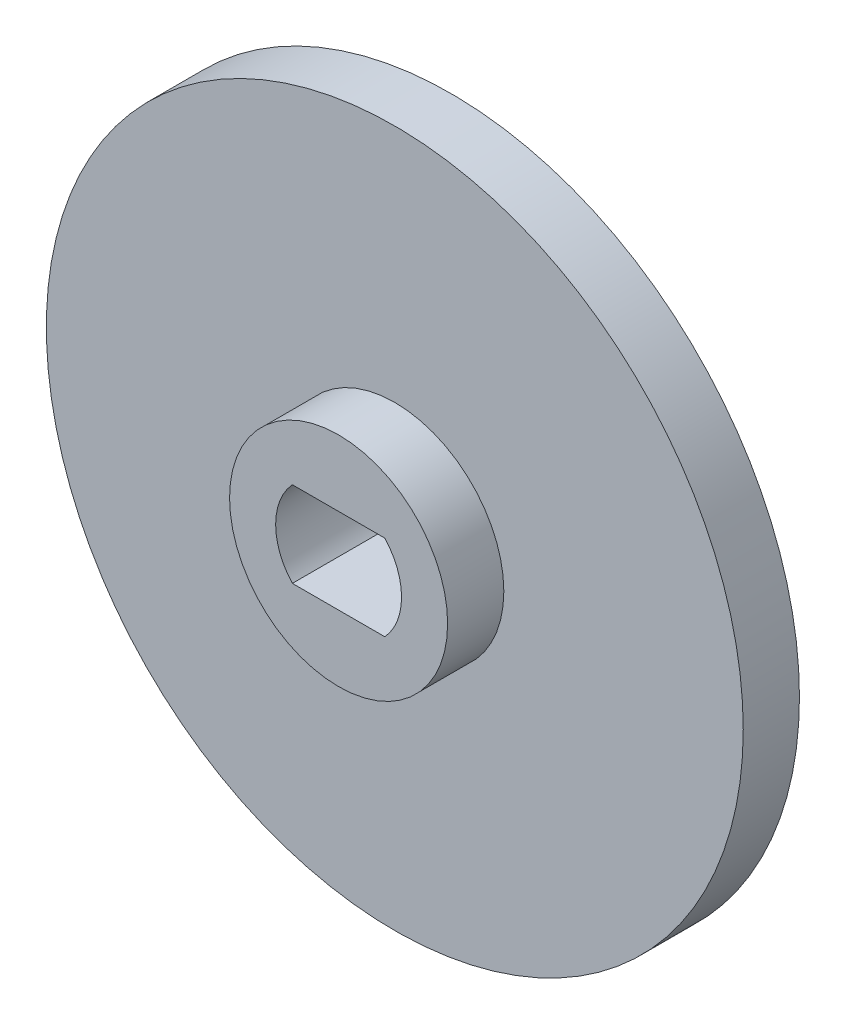
from build123d import *

# Parameters (mm, degrees)
SKETCH1_R           = 15.5
BOSS_EXTRUDE1_DEPTH = 2.5
BOSS_EXTRUDE2_DEPTH = 1.9
CIRPATTERN1_COUNT   = 5
BOSS_EXTRUDE3_START = 2.5
SKETCH3_R           = 4.85
BOSS_EXTRUDE3_DEPTH = 2.5
CUT_EXTRUDE2_DEPTH  = 7.9


with BuildPart() as part:
    # Sketch1 → Boss-Extrude1 (new body)
    with BuildSketch(Plane.XY):
        Circle(SKETCH1_R)
    extrude(amount=BOSS_EXTRUDE1_DEPTH)

    # Sketch2 → Boss-Extrude2 (add)
    with BuildSketch(Plane(origin=(0, 0, 0), x_dir=(-1, 0, 0), z_dir=(0, 0, -1))):
        with BuildLine():
            Line((-7.817353518, 8.129035943), (-3.552701535, 4.927044661))
            ThreePointArc((-3.552701535, 4.927044661), (-3.081541521, 4.749426556), (-2.588715364, 4.852685109))
            ThreePointArc((-2.588715364, 4.852685109), (-1.571286021, 5.27077416), (-0.491007267, 5.478039053))
            ThreePointArc((-0.491007267, 5.478039053), (-0.022087339, 5.66148946), (0.274905404, 6.068103848))
            Line((0.274905404, 6.068103848), (2.090121325, 11.082582471))
            ThreePointArc((2.090121325, 11.082582471), (2.007658151, 11.864965509), (1.341576089, 12.283603874))
            ThreePointArc((1.341576089, 12.283603874), (-3.530150602, 11.841654752), (-7.848632729, 9.543883635))
            ThreePointArc((-7.848632729, 9.543883635), (-8.176755455, 8.82885995), (-7.817353518, 8.129035943))
        make_face()
    boss_extrude2 = extrude(amount=BOSS_EXTRUDE2_DEPTH)

    # CirPattern1: Boss-Extrude2 ×5 about axis
    cirpattern1_axis = Axis((0, 0, 0), (0, 0, 1))
    for i in range(1, CIRPATTERN1_COUNT):
        add(boss_extrude2.rotate(cirpattern1_axis, i * 360 / CIRPATTERN1_COUNT))

    # Sketch3 → Boss-Extrude3 (add)
    with BuildSketch(Plane.XY.offset(BOSS_EXTRUDE3_START)):
        Circle(SKETCH3_R)
    extrude(amount=BOSS_EXTRUDE3_DEPTH)

    # Sketch5 → Cut-Extrude2 (cut, through all)
    with BuildSketch(Plane.XY.offset(5)):
        with BuildLine():
            Line((-2.05669638, 1.9), (2.05669638, 1.9))
            ThreePointArc((2.05669638, 1.9), (2.8, 0), (2.05669638, -1.9))
            Line((2.05669638, -1.9), (-2.05669638, -1.9))
            ThreePointArc((-2.05669638, -1.9), (-2.8, 0), (-2.05669638, 1.9))
        make_face()
    extrude(amount=-CUT_EXTRUDE2_DEPTH, mode=Mode.SUBTRACT)


solid = part.part
